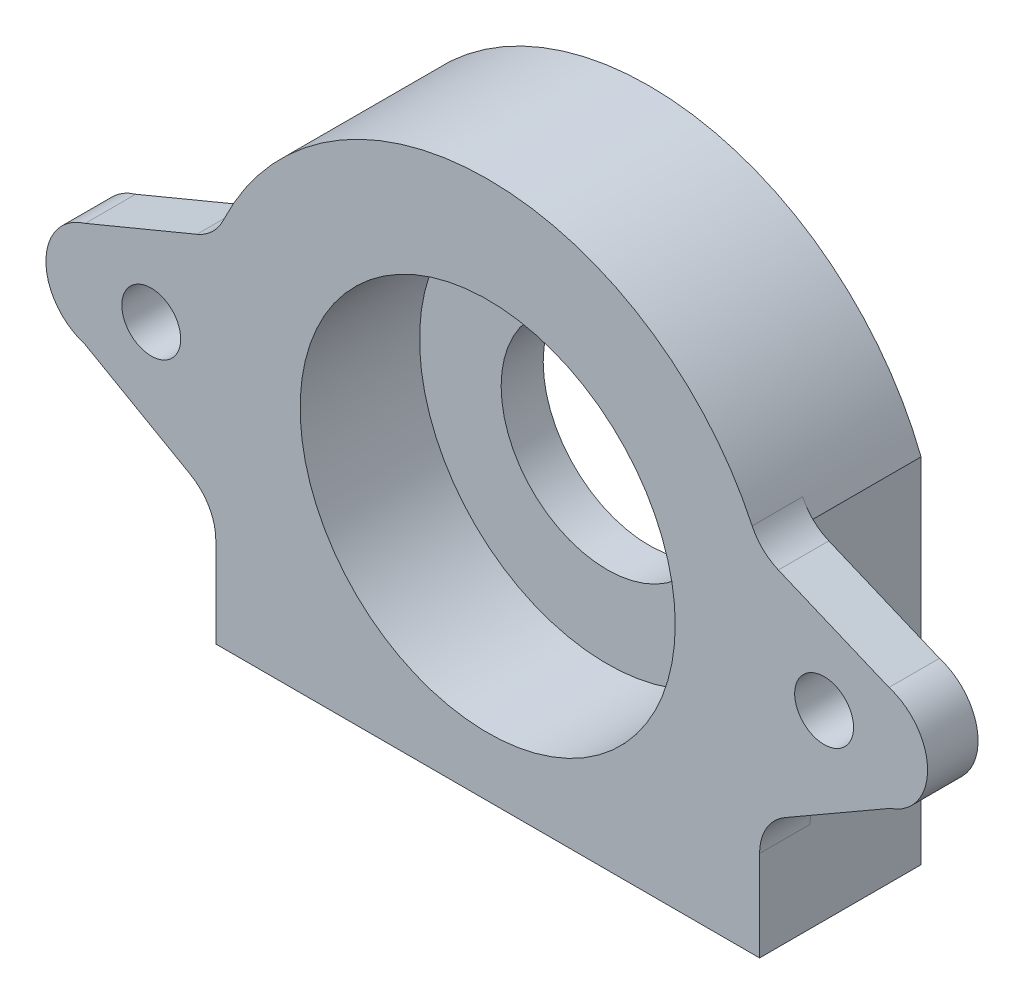
from build123d import *

# Parameters (mm, degrees)
BOSS_EXTRUDE1_DEPTH = 2.5
BOSS_EXTRUDE2_DEPTH = 7.1
SKETCH6_R           = 1.7500000000000002
BOSS_EXTRUDE3_DEPTH = 3
FILLET1_R           = 3
CUT_EXTRUDE2_REACH  = 36.039
SKETCH7_R           = 6.300000000000017
CUT_EXTRUDE5_DEPTH  = 35.03920514623224
SKETCH9_R           = 11.15
BOSS_EXTRUDE4_DEPTH = 7.1
SKETCH10_W          = 32.327700987119805
SKETCH10_H          = 9.6
BOSS_EXTRUDE5_DEPTH = 2


with BuildPart() as part:
    # Sketch2 → Boss-Extrude1 (new body)
    with BuildSketch(Plane.XY):
        with BuildLine():
            Line((-16.1638504935599, 6.342967853027763), (-16.1638504935599, -14.391495343403756))
            Line((-16.1638504935599, -14.391495343403756), (-14.353897968517204, -14.640433541189916))
            Line((-14.353897968517204, -14.640433541189916), (-10.527602773342224, -17.52375378240297))
            Line((-10.527602773342224, -17.52375378240297), (-10.527602773341918, -19.404011272479938))
            Line((-10.527602773341918, -19.404011272479938), (-5.00712834909531, -19.40401127247995))
            Line((-5.00712834909531, -19.40401127247995), (-5.00712834909531, -17.50759675782326))
            Line((-5.00712834909531, -17.50759675782326), (5.000000000000001, -17.50759675782326))
            Line((5.000000000000001, -17.50759675782326), (5.000000000000002, -19.411447251383162))
            Line((5.000000000000002, -19.411447251383162), (10.46723706743368, -19.411447251383162))
            Line((10.46723706743368, -19.411447251383162), (10.46723706743368, -17.567178369014574))
            Line((10.46723706743368, -17.567178369014574), (14.33922382003656, -14.649427069646295))
            Line((14.33922382003656, -14.649427069646295), (16.163850493559902, -14.424396196711085))
            Line((16.163850493559902, -14.424396196711085), (16.163850493559902, 6.3429678530277736))
            ThreePointArc((16.163850493559902, 6.3429678530277736), (11.492625638566038, 13.016253681243118), (4.292170886786073, 16.82499845590859))
            ThreePointArc((4.292170886786073, 16.82499845590859), (-5.6e-16, 17.363850493559898), (-4.292170886786075, 16.824998455908585))
            ThreePointArc((-4.292170886786075, 16.824998455908585), (-11.492625638566041, 13.016253681243107), (-16.1638504935599, 6.342967853027763))
        make_face()
    extrude(amount=BOSS_EXTRUDE1_DEPTH)

    # Sketch3 → Boss-Extrude2 (add)
    with BuildSketch(Plane.XY.offset(2.5)):
        with BuildLine():
            Line((-16.163850493559902, 6.342967853027761), (-16.1638504935599, -14.391495343403756))
            Line((-16.1638504935599, -14.391495343403756), (-14.353897968517204, -14.640433541189916))
            Line((-14.353897968517204, -14.640433541189916), (-10.527602773342224, -17.52375378240297))
            Line((-10.527602773342224, -17.52375378240297), (-10.527602773341918, -19.404011272479938))
            Line((-10.527602773341918, -19.404011272479938), (-5.00712834909531, -19.40401127247995))
            Line((-5.00712834909531, -19.40401127247995), (-5.00712834909531, -17.50759675782326))
            Line((-5.00712834909531, -17.50759675782326), (5.000000000000001, -17.50759675782326))
            Line((5.000000000000001, -17.50759675782326), (5.000000000000002, -19.411447251383162))
            Line((5.000000000000002, -19.411447251383162), (10.46723706743368, -19.411447251383162))
            Line((10.46723706743368, -19.411447251383162), (10.46723706743368, -17.567178369014574))
            Line((10.46723706743368, -17.567178369014574), (14.33922382003656, -14.649427069646295))
            Line((14.33922382003656, -14.649427069646295), (16.163850493559902, -14.424396196711085))
            Line((16.163850493559902, -14.424396196711085), (16.1638504935599, 6.342967853027773))
            ThreePointArc((16.1638504935599, 6.342967853027773), (-6.65e-15, 17.363850493559898), (-16.163850493559902, 6.342967853027761))
        make_face()
        with BuildLine():
            Line((-14.363850493559898, 5.992765737499147), (-14.363850493559898, -12.822119287624734))
            Line((-14.363850493559898, -12.822119287624734), (-13.644664568054253, -12.921035057895738))
            Line((-13.644664568054253, -12.921035057895738), (-8.72760277334237, -16.626306887906704))
            Line((-8.72760277334237, -16.626306887906704), (-8.72760277334221, -17.60401127247994))
            Line((-8.72760277334221, -17.60401127247994), (-6.80712834909531, -17.604011272479944))
            Line((-6.80712834909531, -17.604011272479944), (-6.80712834909531, -15.707596757823262))
            Line((-6.80712834909531, -15.707596757823262), (6.800000000000001, -15.707596757823262))
            Line((6.800000000000001, -15.707596757823262), (6.800000000000002, -17.611447251383158))
            Line((6.800000000000002, -17.611447251383158), (8.667237067433682, -17.611447251383158))
            Line((8.667237067433682, -17.611447251383158), (8.667237067433682, -16.6697314745184))
            Line((8.667237067433682, -16.6697314745184), (13.640731753403138, -12.921934410741372))
            Line((13.640731753403138, -12.921934410741372), (14.3638504935599, -12.832752309167102))
            Line((14.3638504935599, -12.832752309167102), (14.3638504935599, 5.99276573749915))
            ThreePointArc((14.3638504935599, 5.99276573749915), (10.460467666070398, 11.524411411997598), (4.577751284666915, 14.875403704155904))
            ThreePointArc((4.577751284666915, 14.875403704155904), (-2.56e-15, 15.563850493559903), (-4.577751284666914, 14.8754037041559))
            ThreePointArc((-4.577751284666914, 14.8754037041559), (-10.460467666070397, 11.524411411997596), (-14.363850493559898, 5.992765737499147))
        make_face(mode=Mode.SUBTRACT)
    extrude(amount=BOSS_EXTRUDE2_DEPTH)

    # Sketch6 → Boss-Extrude3 (add)
    # profile 1 of 2: a face of its own
    with BuildSketch(Plane.XY.offset(9.6)):
        with BuildLine():
            Line((-16.163850493559902, -7.542701658313458), (-16.163850493559902, 6.342967853027761))
            Line((-16.163850493559902, 6.342967853027761), (-23.929756214170595, 3.117786469903069))
            ThreePointArc((-23.929756214170595, 3.117786469903069), (-26.262186338368657, 0.00976998259598626), (-23.948484603893608, -3.1122135300969274))
            Line((-23.948484603893608, -3.1122135300969274), (-16.163850493559902, -7.542701658313458))
        make_face()
        with Locations((-20, 0)):
            Circle(SKETCH6_R, mode=Mode.SUBTRACT)
    # profile 2 of 2: a face of its own
    with BuildSketch(Plane.XY.offset(9.6)):
        with BuildLine():
            Line((16.163850493559902, -7.542701658313497), (16.163850493559902, 6.3429678530277736))
            Line((16.163850493559902, 6.3429678530277736), (23.859195056542305, 3.1177864699030087))
            ThreePointArc((23.859195056542305, 3.1177864699030087), (26.152039317100943, 0.04687299892404297), (23.92587050194897, -3.072712992175038))
            Line((23.92587050194897, -3.072712992175038), (16.163850493559902, -7.542701658313497))
        make_face()
        with Locations((20, 0)):
            Circle(SKETCH6_R, mode=Mode.SUBTRACT)
    extrude(amount=-BOSS_EXTRUDE3_DEPTH)

    # Fillet1
    fillet1_edges = [part.edges().sort_by_distance(p)[0] for p in [
        (16.163850493559902, -7.542701658313497, 8.1),
        (-16.163850493559902, -7.542701658313458, 8.1),
        (16.1638504935599, 6.342967853027773, 8.1),
        (-16.163850493559902, 6.342967853027762, 8.1),
    ]]
    fillet(fillet1_edges, radius=FILLET1_R)

    # Sketch7 → Cut-Extrude2 (cut, up to next)
    with BuildSketch(Plane(origin=(0, 0, 0), x_dir=(-1, 0, 0), z_dir=(0, 0, -1)), mode=Mode.PRIVATE) as cut_extrude2_sk1:
        Circle(SKETCH7_R)
    cut_extrude2_tool1 = extrude(cut_extrude2_sk1.sketch, amount=-CUT_EXTRUDE2_REACH, mode=Mode.PRIVATE) & part.part
    add(cut_extrude2_tool1.solids().sort_by_distance((0, 0, 0))[0], mode=Mode.SUBTRACT)

    # Sketch4 → Cut-Extrude5 (cut, through all)
    with BuildSketch(Plane(origin=(0, 0, 9.6), x_dir=(-1, 0, 0), z_dir=(0, 0, -1))):
        Polygon((-16.163850493559902, -12.655902988328881), (17.617388614013404, -12.655902988328881), (17.617388614013407, -23.466434072446418), (-16.163850493559902, -23.466434072446418), align=None)
    extrude(amount=CUT_EXTRUDE5_DEPTH, mode=Mode.SUBTRACT)

    # Sketch9 → Boss-Extrude4 (add)
    with BuildSketch(Plane.XY.offset(2.5)):
        with BuildLine():
            Line((-14.363850493559875, 5.992765737499137), (-14.363850493559898, -12.655902988328881))
            Line((-14.363850493559898, -12.655902988328881), (14.3638504935599, -12.655902988328881))
            Line((14.3638504935599, -12.655902988328881), (14.363850493559902, 5.992765737499152))
            ThreePointArc((14.363850493559902, 5.992765737499152), (9e-16, 15.563850493559924), (-14.363850493559875, 5.992765737499137))
        make_face()
        Circle(SKETCH9_R, mode=Mode.SUBTRACT)
    extrude(amount=BOSS_EXTRUDE4_DEPTH)

    # Sketch10 → Boss-Extrude5 (add)
    with BuildSketch(Plane.XZ.offset(12.655902988328881)):
        with Locations((0, 4.8)):
            Rectangle(SKETCH10_W, SKETCH10_H)
    extrude(amount=BOSS_EXTRUDE5_DEPTH)


solid = part.part
